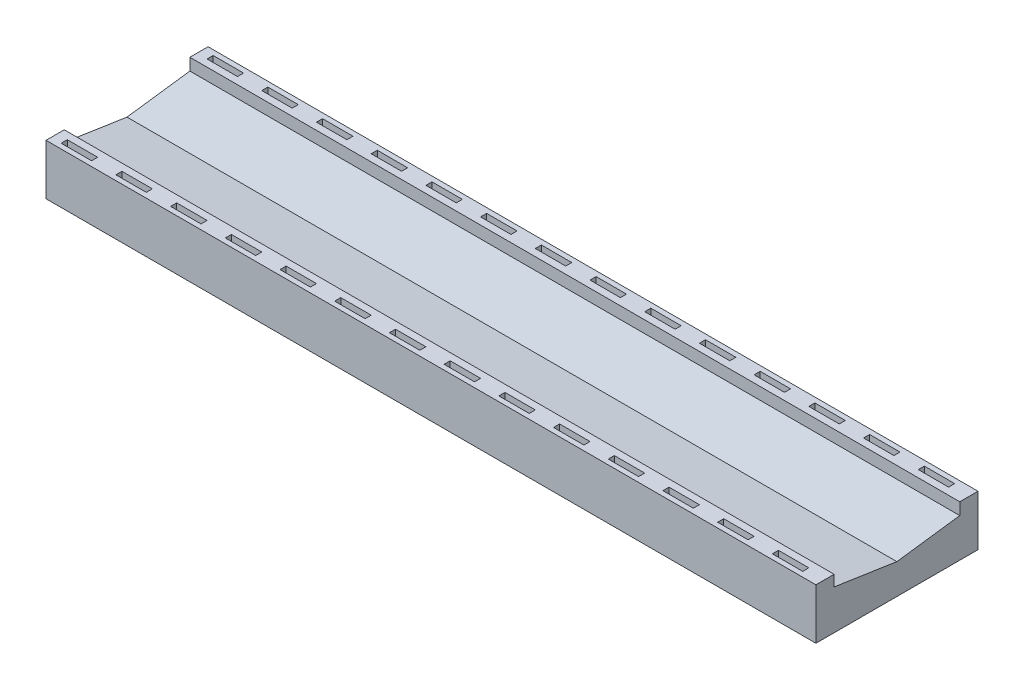
from build123d import *

# Parameters (mm, degrees)
SKETCH1_W               = 38
SKETCH1_H               = 8
BOSS_EXTRUDE1_DEPTH     = 2.5
SKETCH2_W               = 1.5
SKETCH2_H               = 0.3
CUT_EXTRUDE1_DEPTH      = 2
LPATTERN1_COUNT         = 14
LPATTERN1_PITCH         = 2.7
LPATTERN1_COUNT_DIR2    = 2
LPATTERN1_PITCH_DIR2    = 7.2
CUT_EXTRUDE3_DEPTH      = 1
CUT_EXTRUDE3_DEPTH_BACK = 39


with BuildPart() as part:
    # Sketch1 → Boss-Extrude1 (new body)
    with BuildSketch(Plane(origin=(0, 0, 0), x_dir=(1, 0, 0), z_dir=(0, 1, 0))):
        with Locations((19, 4)):
            Rectangle(SKETCH1_W, SKETCH1_H)
    extrude(amount=BOSS_EXTRUDE1_DEPTH)

    # Sketch2 → Cut-Extrude1 (cut)
    with BuildSketch(Plane(origin=(0, 2.5, 0), x_dir=(1, 0, 0), z_dir=(0, 1, 0))):
        with Locations((1.25, 0.4)):
            Rectangle(SKETCH2_W, SKETCH2_H)
    cut_extrude1 = extrude(amount=-CUT_EXTRUDE1_DEPTH, mode=Mode.SUBTRACT)

    # LPattern1: Cut-Extrude1 14 × 2
    with Locations(*[(i * LPATTERN1_PITCH, 0, -j * LPATTERN1_PITCH_DIR2) for i in range(LPATTERN1_COUNT) for j in range(LPATTERN1_COUNT_DIR2) if (i, j) != (0, 0)]):
        add(cut_extrude1, mode=Mode.SUBTRACT)

    # Sketch3 → Cut-Extrude3 (cut, two sides)
    with BuildSketch(Plane.ZY) as cut_extrude3_sk:
        Polygon((-7.1, 27.554567413), (-7.1, 2.5), (-7.1, 1.909233449), (-3.996408042, 1.492540175), (-0.9, 1.959630707), (-0.9, 2.5), (-0.9, 27.554567413), (-0.9, 77.66370224), (-7.1, 77.66370224), align=None)
    extrude(amount=CUT_EXTRUDE3_DEPTH, mode=Mode.SUBTRACT)
    extrude(cut_extrude3_sk.sketch, amount=-CUT_EXTRUDE3_DEPTH_BACK, mode=Mode.SUBTRACT)


solid = part.part
